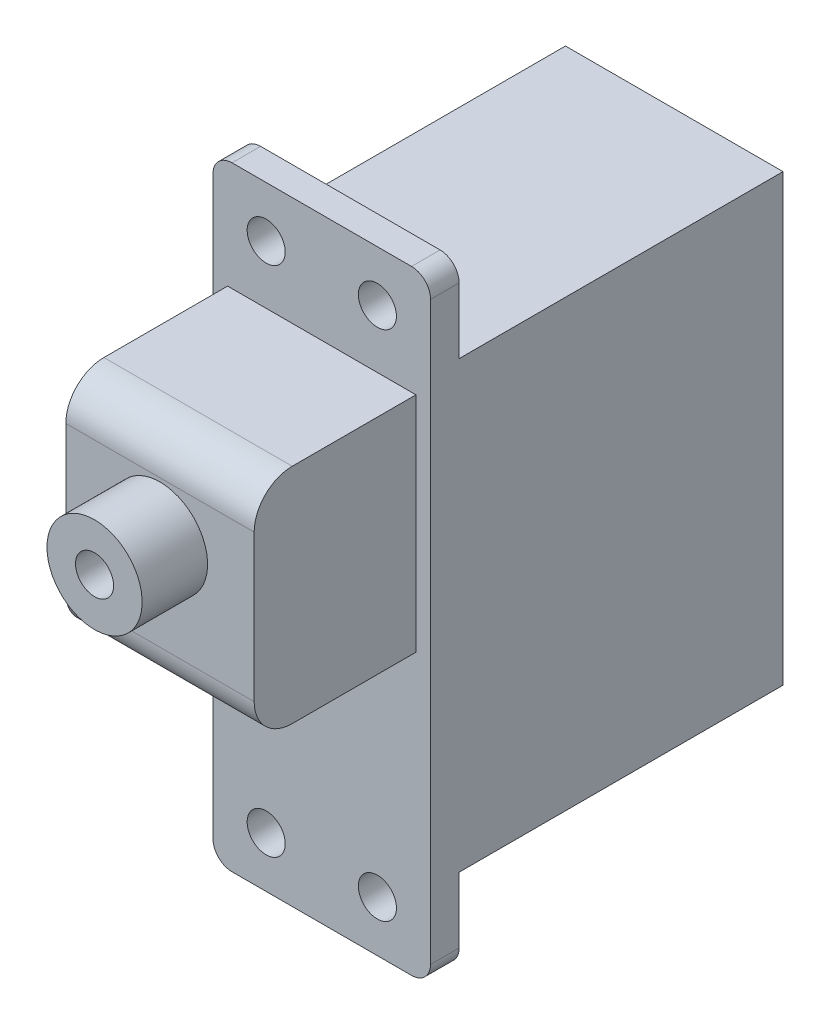
from build123d import *

# Parameters (mm, degrees)
ESQUISSE1_W                       = 18.518
ESQUISSE1_H                       = 32.258
BOSS_EXTRU_1_DEPTH                = 11.43
ESQUISSE2_W                       = 17.018000001
ESQUISSE2_H                       = 4.44499999
ENL_V_MAT_EXTRU_1_DEPTH           = 12.43
ESQUISSE3_W                       = 17.018000001
ESQUISSE3_H                       = 4.44499999
ENL_V_MAT_EXTRU_2_DEPTH           = 12.43
ESQUISSE4_W                       = 9.89372273
ESQUISSE4_H                       = 11.711081898
BOSS_EXTRU_2_DEPTH                = 8.5
ESQUISSE5_W                       = 2.5
ESQUISSE5_H                       = 3.438
DIAM_TRE_DU_PER_AGE_2_0_2_1_D     = 2
DIAM_TRE_DU_PER_AGE_2_0_2_1_DEPTH = 2
DIAM_TRE_DU_PER_AGE_2_0_2_2_D     = 2
DIAM_TRE_DU_PER_AGE_2_0_2_2_DEPTH = 13.438
CONG_1_R                          = 1
CONG_2_R                          = 2


with BuildPart() as part:
    # Esquisse1 → Boss.-Extru.1 (new body)
    with BuildSketch(Plane(origin=(11.43, 0, 0), x_dir=(0, 0, -1), z_dir=(1, 0, 0))):
        with Locations((7.759, 11.684)):
            Rectangle(ESQUISSE1_W, ESQUISSE1_H)
    extrude(amount=-BOSS_EXTRU_1_DEPTH)

    # Esquisse2 → Enlèv. mat.-Extru.1 (cut, through all)
    with BuildSketch(Plane.ZY):
        with Locations((-8.509, -2.222500005)):
            Rectangle(ESQUISSE2_W, ESQUISSE2_H)
    extrude(amount=-ENL_V_MAT_EXTRU_1_DEPTH, mode=Mode.SUBTRACT)

    # Esquisse3 → Enlèv. mat.-Extru.2 (cut, through all)
    with BuildSketch(Plane.ZY):
        with Locations((-8.509, 25.590500005)):
            Rectangle(ESQUISSE3_W, ESQUISSE3_H)
    extrude(amount=-ENL_V_MAT_EXTRU_2_DEPTH, mode=Mode.SUBTRACT)

    # Esquisse4 → Boss.-Extru.2 (add)
    with BuildSketch(Plane.XY.offset(1.5)):
        with Locations((5.715, 16.232232421)):
            Rectangle(ESQUISSE4_W, ESQUISSE4_H)
    extrude(amount=BOSS_EXTRU_2_DEPTH)

    # Esquisse5 → Révolution1 (revolve)
    with BuildSketch(Plane.XZ.offset(-17.399)):
        with Locations((6.965, 11.719)):
            Rectangle(ESQUISSE5_W, ESQUISSE5_H)
    revolve(axis=Axis((5.715, 17.399, 13.438), (0, 0, -1)))

    # Diamètre du perçage Ø2.0 (2)1
    with Locations(Plane.XY.offset(13.438)):
        with Locations((5.715, 17.399)):
            Hole(DIAM_TRE_DU_PER_AGE_2_0_2_1_D / 2, depth=DIAM_TRE_DU_PER_AGE_2_0_2_1_DEPTH)

    # Diamètre du perçage Ø2.0 (2)2
    with Locations(Plane(origin=(0, 0, 0), x_dir=(-1, 0, 0), z_dir=(0, 0, -1))):
        with Locations((-2.794, -1.778), (-8.636, -1.778), (-8.636, 25.146), (-2.794, 25.146)):
            Hole(DIAM_TRE_DU_PER_AGE_2_0_2_2_D / 2, depth=DIAM_TRE_DU_PER_AGE_2_0_2_2_DEPTH)

    # Congé1
    cong_1_edges = [part.edges().sort_by_distance(p)[0] for p in [
        (11.43, 27.813, 0.750000001),
        (0, 27.813, 0.750000001),
        (11.43, -4.445, 0.750000001),
        (0, -4.445, 0.750000001),
    ]]
    fillet(cong_1_edges, radius=CONG_1_R)

    # Congé2
    cong_2_edges = [part.edges().sort_by_distance(p)[0] for p in [
        (5.715, 10.376691472, 10),
        (5.715, 22.08777337, 10),
    ]]
    fillet(cong_2_edges, radius=CONG_2_R)


solid = part.part
